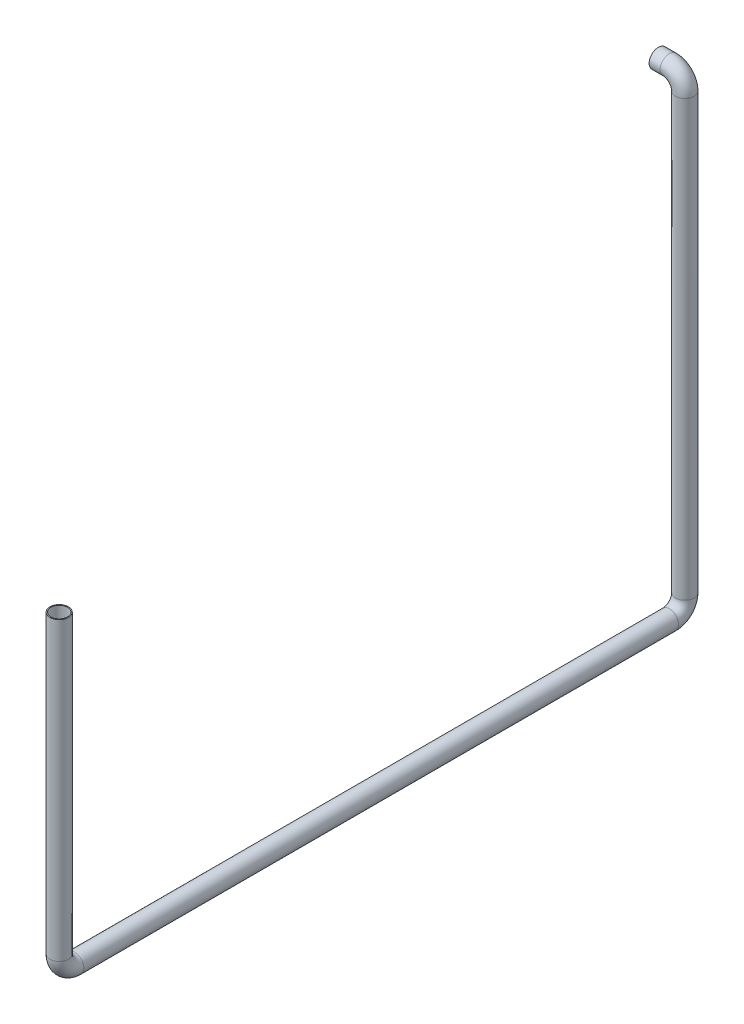
from build123d import *

# Parameters (mm, degrees)
SWEEP_THIN1_PROFILE_R   = 30
SWEEP_THIN1_PROFILE_R_2 = 27


with BuildPart() as part:
    # Sweep-Thin1: sweep along a curve in space
    with BuildLine() as sweep_thin1_path:
        Line((-29015.617683291, -12281.065459453, 42898.300196057), (-29015.617683291, -13240.451275542, 42898.300196057))
        ThreePointArc((-29015.617683291, -13290.451275542, 42848.300196057), (-29015.617683291, -13275.806614601, 42883.655535116), (-29015.617683291, -13240.451275542, 42898.300196057))
        Line((-29015.617683291, -13290.451275542, 42848.300196057), (-29015.617683291, -13290.451275542, 40920.700196057))
        ThreePointArc((-29015.617683291, -13240.451275542, 40870.700196057), (-29015.617683291, -13275.806614601, 40885.344856997), (-29015.617683291, -13290.451275542, 40920.700196057))
        Line((-29015.617683291, -13240.451275542, 40870.700196057), (-29015.617683291, -11832.518633414, 40870.700196057))
        ThreePointArc((-29065.617683291, -11782.518633414, 40870.700196057), (-29030.262344232, -11797.163294355, 40870.700196057), (-29015.617683291, -11832.518633414, 40870.700196057))
        Line((-29101.320791483, -11782.518633414, 40870.700196057), (-29065.617683291, -11782.518633414, 40870.700196057))
    # Sweep-Thin1 profile (on start of the path) → Sweep-Thin1 (sweep)
    with BuildSketch(Plane(origin=(-29015.617683291, -12281.065459453, 42898.300196057), x_dir=(0, 0, -1), z_dir=(0, -1, 0))):
        Circle(SWEEP_THIN1_PROFILE_R)
        Circle(SWEEP_THIN1_PROFILE_R_2, mode=Mode.SUBTRACT)
    sweep(path=sweep_thin1_path.line)


solid = part.part
